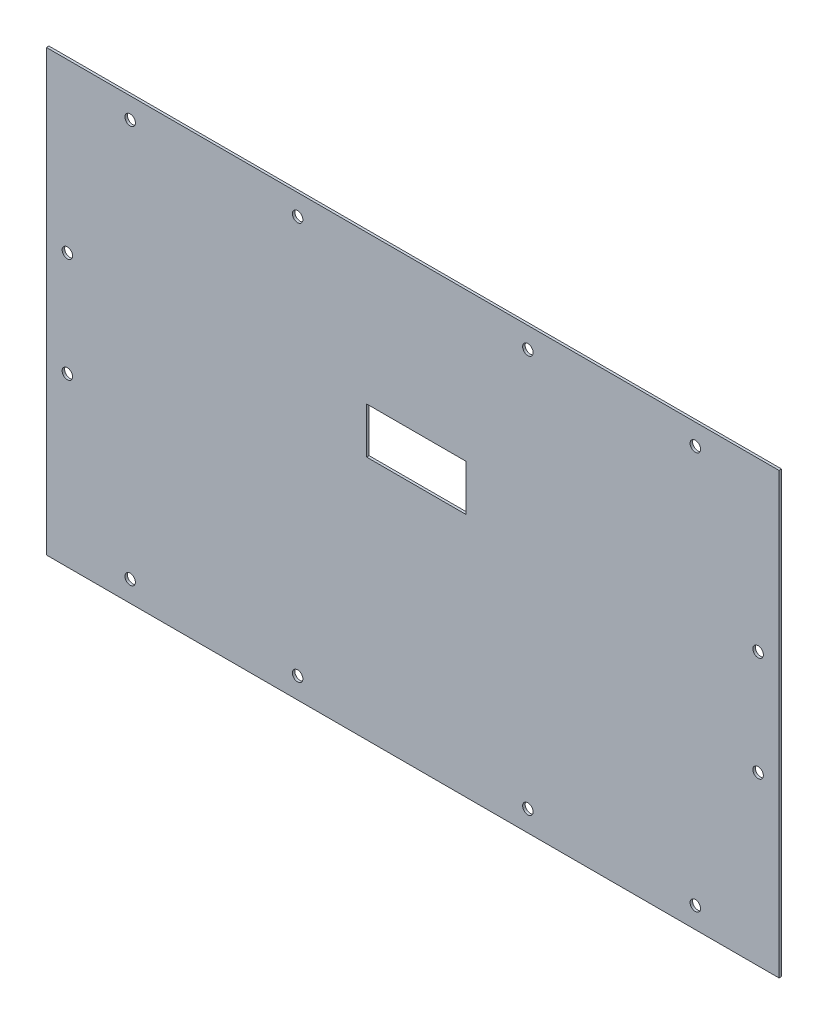
from build123d import *

# Parameters (mm, degrees)
SURFACE_EXTRUDE1_1_DEPTH = 350
THICKEN1_T1              = 1.2
SKETCH2_W                = 47.5
SKETCH2_H                = 22
CUT_EXTRUDE1_DEPTH       = 10
SKETCH3_R                = 2.5
CUT_EXTRUDE2_DEPTH       = 10


with BuildPart() as body_1:
    # Surface-Extrude1: a surface, the sketch's curves swept straight by 350 mm
    with BuildLine(Plane(origin=(0, 0, 0), x_dir=(0, 0, -1), z_dir=(1, 0, 0)), mode=Mode.PRIVATE) as surface_extrude1_1_path:
        Line((0, 0), (0, 210))
    surface_extrude1_1 = Shell.extrude(surface_extrude1_1_path.wire(), (1 * SURFACE_EXTRUDE1_1_DEPTH, 0 * SURFACE_EXTRUDE1_1_DEPTH, 0 * SURFACE_EXTRUDE1_1_DEPTH))
    add(Solid.thicken(surface_extrude1_1, THICKEN1_T1))

    # Sketch2 → Cut-Extrude1 (cut)
    with BuildSketch(Plane.XY.offset(1.2)):
        with Locations((176.75, 128)):
            Rectangle(SKETCH2_W, SKETCH2_H)
    extrude(amount=-CUT_EXTRUDE1_DEPTH, mode=Mode.SUBTRACT)

    # Sketch3 → Cut-Extrude2 (cut)
    with BuildSketch(Plane(origin=(0, 0, 0), x_dir=(-1, 0, 0), z_dir=(0, 0, -1))):
        with Locations((-310, 200)):
            Circle(SKETCH3_R)
        with Locations((-230, 200)):
            Circle(SKETCH3_R)
        with Locations((-340, 130)):
            Circle(SKETCH3_R)
        with Locations((-10, 130)):
            Circle(SKETCH3_R)
        with Locations((-120, 200)):
            Circle(SKETCH3_R)
        with Locations((-40, 200)):
            Circle(SKETCH3_R)
        with Locations((-10, 80)):
            Circle(SKETCH3_R)
        with Locations((-40, 10)):
            Circle(SKETCH3_R)
        with Locations((-120, 10)):
            Circle(SKETCH3_R)
        with Locations((-230, 10)):
            Circle(SKETCH3_R)
        with Locations((-310, 10)):
            Circle(SKETCH3_R)
        with Locations((-340, 80)):
            Circle(SKETCH3_R)
    extrude(amount=-CUT_EXTRUDE2_DEPTH, mode=Mode.SUBTRACT)


solid = body_1.part
